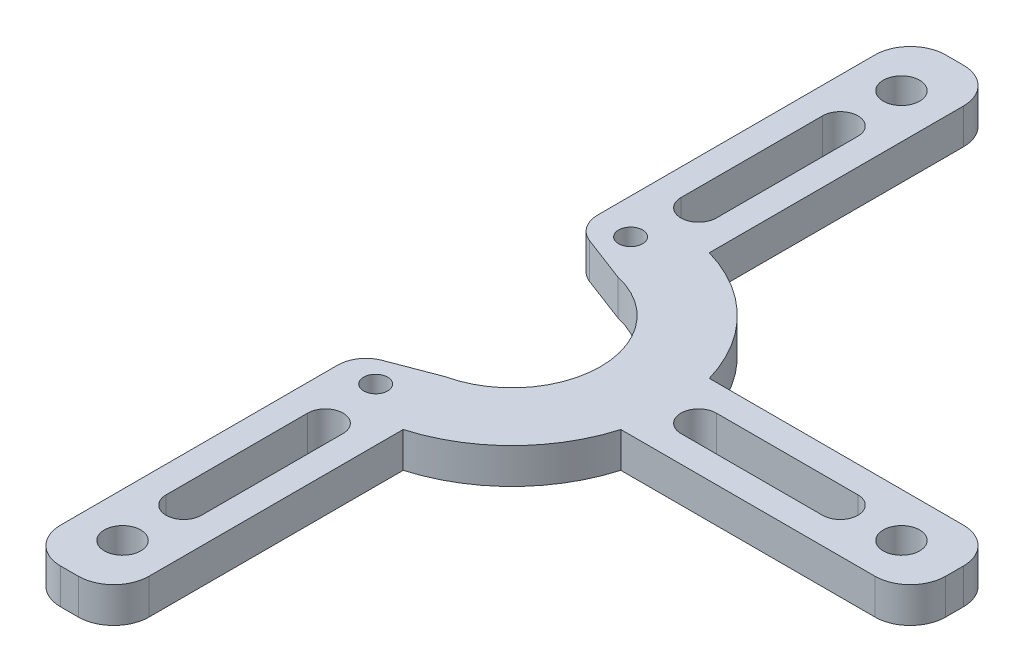
from build123d import *

# Parameters (mm, degrees)
SKETCH1_R                = 28.575
SKETCH1_R_2              = 15.875
BOSS_EXTRUDE1_DEPTH      = 6.35
BOSS_EXTRUDE2_DEPTH      = 6.35
F_0_257_DIAMETER_HOLE1_D = 6.5278
CIRPATTERN1_COUNT        = 4
CUT_EXTRUDE1_DEPTH       = 7.35
FILLET1_R                = 5.08
SKETCH6_R                = 2.15265
CUT_EXTRUDE2_DEPTH       = 7.35


with BuildPart() as part:
    # Sketch1 → Boss-Extrude1 (new body)
    with BuildSketch(Plane(origin=(0, 0, 0), x_dir=(1, 0, 0), z_dir=(0, 1, 0))):
        Circle(SKETCH1_R)
        Circle(SKETCH1_R_2, mode=Mode.SUBTRACT)
    extrude(amount=BOSS_EXTRUDE1_DEPTH)

    # Sketch2 → Boss-Extrude2 (add)
    with BuildSketch(Plane(origin=(0, 6.35, 0), x_dir=(1, 0, 0), z_dir=(0, 1, 0))):
        with BuildLine():
            Line((73.025, -7.9375), (25.4, -7.9375))
            Line((25.4, -7.9375), (25.4, 7.9375))
            Line((25.4, 7.9375), (73.025, 7.9375))
            ThreePointArc((73.025, 7.9375), (77.515128061, 6.077628061), (79.375, 1.5875))
            Line((79.375, 1.5875), (79.375, -1.5875))
            ThreePointArc((79.375, -1.5875), (77.515128061, -6.077628061), (73.025, -7.9375))
        make_face()
        with BuildLine():
            Line((58.870802517, -3.175), (33.470802517, -3.175))
            ThreePointArc((33.470802517, -3.175), (30.295802517, 0), (33.470802517, 3.175))
            Line((33.470802517, 3.175), (58.870802517, 3.175))
            ThreePointArc((58.870802517, 3.175), (62.045802517, 0), (58.870802517, -3.175))
        make_face(mode=Mode.SUBTRACT)
    boss_extrude2 = extrude(amount=-BOSS_EXTRUDE2_DEPTH)

    # F (0.257) Diameter Hole1 (through all)
    with Locations(Plane(origin=(0, 6.35, 0), x_dir=(1, 0, 0), z_dir=(0, 1, 0))):
        with Locations((69.85, 0)):
            f_0_257_diameter_hole1 = Hole(F_0_257_DIAMETER_HOLE1_D / 2)

    # CirPattern1: Boss-Extrude2, F (0.257) Diameter Hole1 ×4 about axis
    cirpattern1_axis = Axis((0, 0, 0), (0, 1, 0))
    for i in range(1, CIRPATTERN1_COUNT):
        add(boss_extrude2.rotate(cirpattern1_axis, i * 360 / CIRPATTERN1_COUNT))
        add(f_0_257_diameter_hole1.rotate(cirpattern1_axis, i * 360 / CIRPATTERN1_COUNT), mode=Mode.SUBTRACT)

    # Sketch5 → Cut-Extrude1 (cut, through all)
    with BuildSketch(Plane(origin=(0, 6.35, 0), x_dir=(1, 0, 0), z_dir=(0, 1, 0))):
        Polygon((-7.9375, 19.830441139), (-7.9375, 27.450441139), (-7.9375, 52.536571615), (-88.152777481, 52.536571615), (-88.152777481, -52.536571615), (-7.9375, -52.536571615), (-7.9375, -27.450441139), (-7.9375, -19.830441139), (3.4925, -15.486060466), (3.4925, 15.486060466), align=None)
    extrude(amount=-CUT_EXTRUDE1_DEPTH, mode=Mode.SUBTRACT)

    # Fillet1
    fillet1_edges = [part.edges().sort_by_distance(p)[0] for p in [
        (-7.9375, 3.175, 19.830441139),
        (-7.9375, 3.175, -19.830441139),
    ]]
    fillet(fillet1_edges, radius=FILLET1_R)

    # Sketch6 → Cut-Extrude2 (cut, through all)
    with BuildSketch(Plane(origin=(0, 6.35, 0), x_dir=(1, 0, 0), z_dir=(0, 1, 0))):
        with Locations((-1.5875, 22.86)):
            Circle(SKETCH6_R)
        with Locations((-1.5875, -22.86)):
            Circle(SKETCH6_R)
    extrude(amount=-CUT_EXTRUDE2_DEPTH, mode=Mode.SUBTRACT)


solid = part.part
